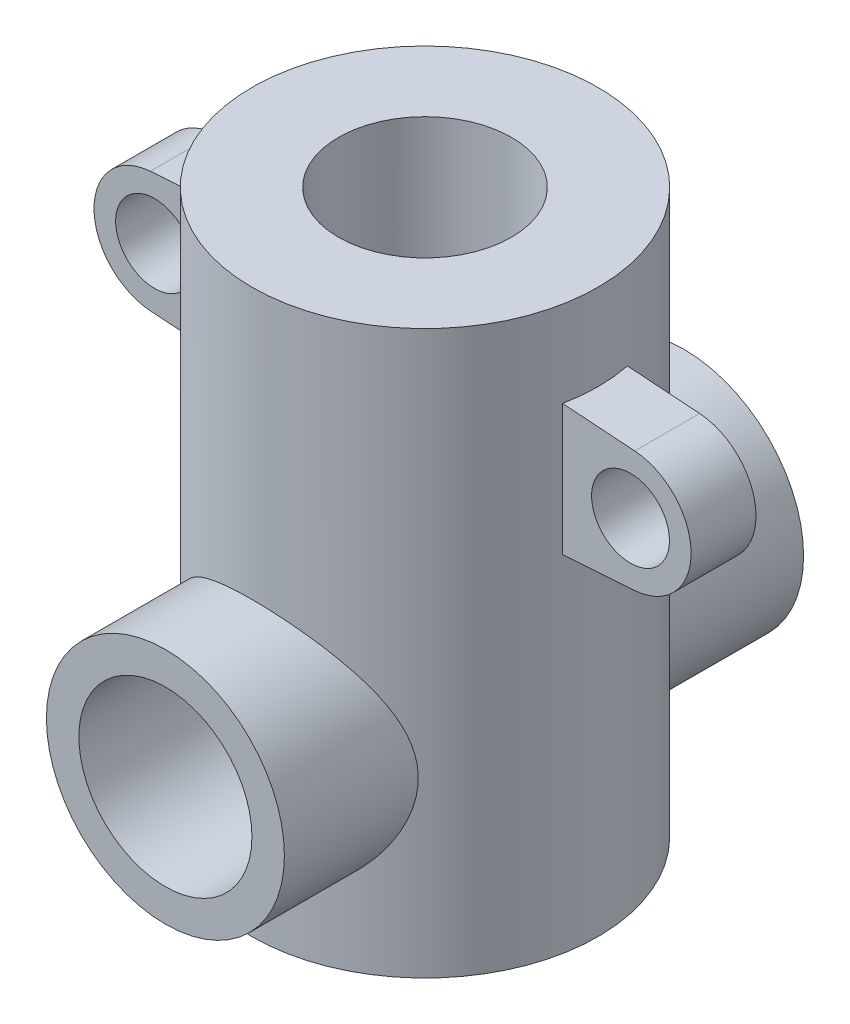
from build123d import *

# Parameters (mm, degrees)
SKETCH1_R                      = 40
SKETCH1_R_2                    = 20
BOSS_EXTRUDE1_DEPTH            = 130
SKETCH2_R                      = 27.5
SKETCH2_R_2                    = 20
BOSS_EXTRUDE2_DEPTH            = 60
SKETCH2_2_R                    = 20
CUT_EXTRUDE1_DEPTH             = 61.0000001
CUT_EXTRUDE1_DEPTH_BACK        = 61.0000001
SKETCH3_R                      = 14
SKETCH3_R_2                    = 9
BOSS_EXTRUDE3_DEPTH            = 7.5
CUT_EXTRUDE2_REACH             = 132
SKETCH4_R                      = 20
CUT_EXTRUDE2_DIRECTION_2_DEPTH = 1.0000001
BOSS_EXTRUDE4_REACH            = 132
SKETCH5_R                      = 20


with BuildPart() as part:
    # Sketch1 → Boss-Extrude1 (new body)
    with BuildSketch(Plane(origin=(0, 0, 0), x_dir=(1, 0, 0), z_dir=(0, 1, 0))):
        Circle(SKETCH1_R)
        Circle(SKETCH1_R_2, mode=Mode.SUBTRACT)
    extrude(amount=BOSS_EXTRUDE1_DEPTH)

    # Sketch2 → Boss-Extrude2 (add, symmetric)
    with BuildSketch(Plane.XY):
        with Locations((0, 40)):
            Circle(SKETCH2_R)
        with Locations((0, 40)):
            Circle(SKETCH2_R_2, mode=Mode.SUBTRACT)
    extrude(amount=BOSS_EXTRUDE2_DEPTH, both=True)

    # Sketch2_2 → Cut-Extrude1 (cut, two sides)
    with BuildSketch(Plane.XY) as cut_extrude1_sk:
        with Locations((0, 40)):
            Circle(SKETCH2_2_R)
    extrude(amount=CUT_EXTRUDE1_DEPTH, mode=Mode.SUBTRACT)
    extrude(cut_extrude1_sk.sketch, amount=-CUT_EXTRUDE1_DEPTH_BACK, mode=Mode.SUBTRACT)

    # Sketch3 → Boss-Extrude3 (add, symmetric)
    with BuildSketch(Plane.XY):
        with Locations((-55, 95)):
            Circle(SKETCH3_R)
        with Locations((-55, 95)):
            Circle(SKETCH3_R_2, mode=Mode.SUBTRACT)
        with BuildLine():
            Line((-25, 111.131990931), (-40, 110.083088752))
            Line((-40, 110.083088752), (-55.976590632, 108.965896704))
            ThreePointArc((-55.976590632, 108.965896704), (-45.452022959, 105.238951823), (-41, 95))
            ThreePointArc((-41, 95), (-45.452022959, 84.761048177), (-55.976590632, 81.034103296))
            Line((-55.976590632, 81.034103296), (-40, 79.916911248))
            Line((-40, 79.916911248), (-25, 78.868009069))
            Line((-25, 78.868009069), (-25, 111.131990931))
        make_face()
        with Locations((55, 95)):
            Circle(SKETCH3_R)
        with Locations((55, 95)):
            Circle(SKETCH3_R_2, mode=Mode.SUBTRACT)
        with BuildLine():
            Line((55.976590632, 108.965896704), (40, 110.083088752))
            Line((40, 110.083088752), (25, 111.131990931))
            Line((25, 111.131990931), (25, 78.868009069))
            Line((25, 78.868009069), (40, 79.916911248))
            Line((40, 79.916911248), (55.976590632, 81.034103296))
            ThreePointArc((55.976590632, 81.034103296), (41, 95), (55.976590632, 108.965896704))
        make_face()
    extrude(amount=BOSS_EXTRUDE3_DEPTH, both=True)

    # Sketch4 → Cut-Extrude2 (cut, up to next)
    with BuildSketch(Plane(origin=(0, 130, 0), x_dir=(1, 0, 0), z_dir=(0, 1, 0)), mode=Mode.PRIVATE) as cut_extrude2_sk1:
        Circle(SKETCH4_R)
    cut_extrude2_tool1 = extrude(cut_extrude2_sk1.sketch, amount=-CUT_EXTRUDE2_REACH, mode=Mode.PRIVATE) & part.part
    add(cut_extrude2_tool1.solids().sort_by_distance((0, 130, 0))[0], mode=Mode.SUBTRACT)

    # Sketch4 → Cut-Extrude2 direction 2 (cut)
    with BuildSketch(Plane(origin=(0, 130, 0), x_dir=(1, 0, 0), z_dir=(0, 1, 0))):
        Circle(SKETCH4_R)
    extrude(amount=CUT_EXTRUDE2_DIRECTION_2_DEPTH, mode=Mode.SUBTRACT)

    # Sketch5 → Boss-Extrude4 (add, up to next)
    with BuildSketch(Plane.XZ, mode=Mode.PRIVATE) as boss_extrude4_sk1:
        Circle(SKETCH5_R)
    boss_extrude4_tool1 = extrude(boss_extrude4_sk1.sketch, amount=-BOSS_EXTRUDE4_REACH, mode=Mode.PRIVATE) - part.part
    add(boss_extrude4_tool1.solids().sort_by_distance((0, 0, 0))[0])


solid = part.part
